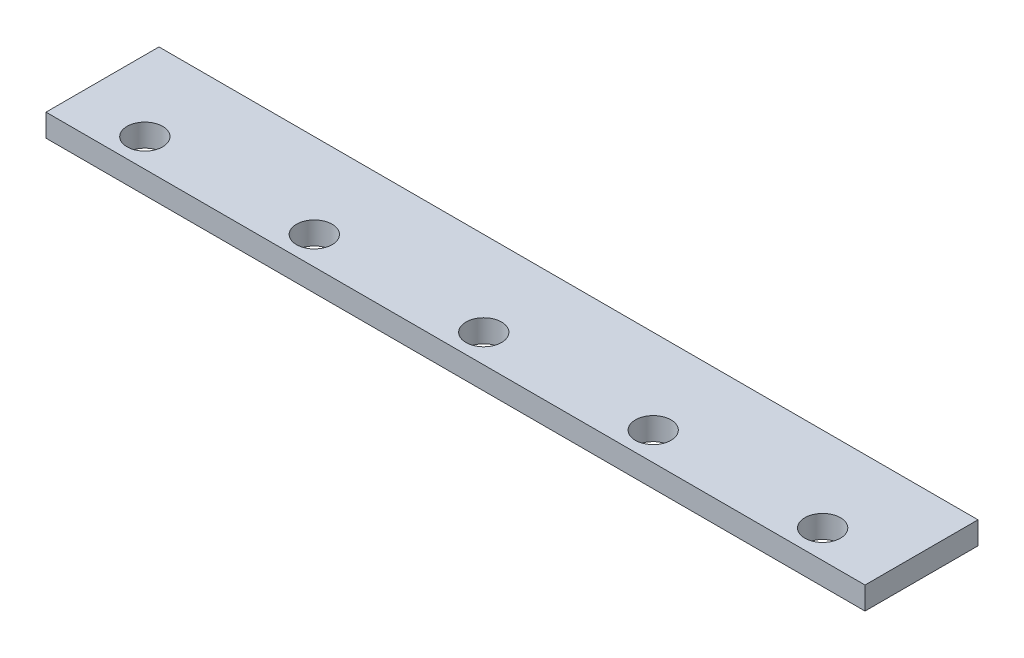
from build123d import *

# Parameters (mm, degrees)
SKETCH1_W           = 580
SKETCH1_H           = 80
BOSS_EXTRUDE1_DEPTH = 16
SKETCH2_R           = 12.6
CUT_EXTRUDE4_DEPTH  = 18
LPATTERN1_COUNT     = 5
LPATTERN1_PITCH     = 120


with BuildPart() as part:
    # Sketch1 → Boss-Extrude1 (new body)
    with BuildSketch(Plane(origin=(0, 0, 0), x_dir=(1, 0, 0), z_dir=(0, 1, 0))):
        with Locations((290, -40)):
            Rectangle(SKETCH1_W, SKETCH1_H)
    extrude(amount=BOSS_EXTRUDE1_DEPTH)

    # Sketch2 → Cut-Extrude4 (cut)
    with BuildSketch(Plane(origin=(0, 0, 0), x_dir=(1, 0, 0), z_dir=(0, 1, 0))):
        with Locations(Location((50, -60, 0), (0, 0, 270))):  # turned: the seam where the file's is
            Circle(SKETCH2_R)
    cut_extrude4 = extrude(amount=CUT_EXTRUDE4_DEPTH, mode=Mode.SUBTRACT)

    # LPattern1: Cut-Extrude4 ×5
    with Locations(*[(i * LPATTERN1_PITCH, 0, 0) for i in range(1, LPATTERN1_COUNT)]):
        add(cut_extrude4, mode=Mode.SUBTRACT)


solid = part.part
